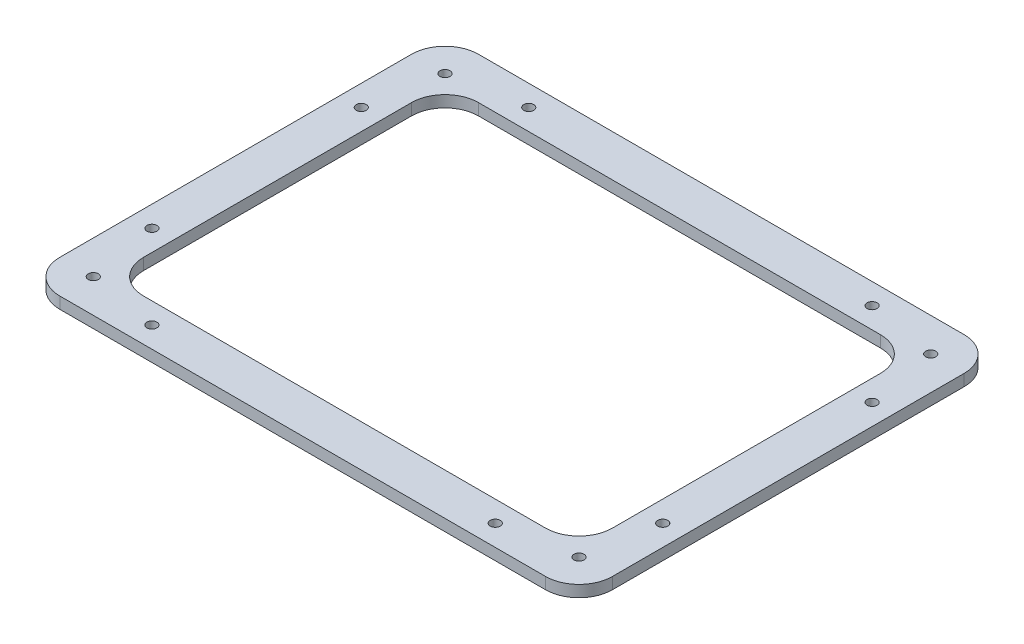
from build123d import *

# Parameters (mm, degrees)
SKETCH1_W           = 330
SKETCH1_H           = 250
BOSS_EXTRUDE1_DEPTH = 6.9
SKETCH2_R           = 3
CUT_EXTRUDE1_DEPTH  = 7.9
SKETCH3_W           = 280
SKETCH3_H           = 200
CUT_EXTRUDE2_DEPTH  = 7.9
FILLET1_R           = 20
FILLET2_R           = 20
SKETCH4_R           = 3
CUT_EXTRUDE3_DEPTH  = 7.9


with BuildPart() as part:
    # Sketch1 → Boss-Extrude1 (new body)
    with BuildSketch(Plane(origin=(0, 0, 0), x_dir=(1, 0, 0), z_dir=(0, 1, 0))):
        Rectangle(SKETCH1_W, SKETCH1_H)
    extrude(amount=BOSS_EXTRUDE1_DEPTH)

    # Sketch2 → Cut-Extrude1 (cut, through all)
    with BuildSketch(Plane(origin=(0, 6.9, 0), x_dir=(1, 0, 0), z_dir=(0, 1, 0))):
        with Locations((-145, 105)):
            Circle(SKETCH2_R)
        with Locations((145, 105)):
            Circle(SKETCH2_R)
        with Locations((145, -105)):
            Circle(SKETCH2_R)
        with Locations((-145, -105)):
            Circle(SKETCH2_R)
    extrude(amount=-CUT_EXTRUDE1_DEPTH, mode=Mode.SUBTRACT)

    # Sketch3 → Cut-Extrude2 (cut, through all)
    with BuildSketch(Plane(origin=(0, 6.9, 0), x_dir=(1, 0, 0), z_dir=(0, 1, 0))):
        Rectangle(SKETCH3_W, SKETCH3_H)
    extrude(amount=-CUT_EXTRUDE2_DEPTH, mode=Mode.SUBTRACT)

    # Fillet1
    fillet1_edges = [part.edges().sort_by_distance(p)[0] for p in [
        (-165, 3.45, -125),
        (165, 3.45, -125),
        (165, 3.45, 125),
        (-165, 3.45, 125),
    ]]
    fillet(fillet1_edges, radius=FILLET1_R)

    # Fillet2
    fillet2_edges = [part.edges().sort_by_distance(p)[0] for p in [
        (-140, 3.45, 100),
        (-140, 3.45, -100),
        (140, 3.45, -100),
        (140, 3.45, 100),
    ]]
    fillet(fillet2_edges, radius=FILLET2_R)

    # Sketch4 → Cut-Extrude3 (cut, through all)
    with BuildSketch(Plane(origin=(0, 6.9, 0), x_dir=(1, 0, 0), z_dir=(0, 1, 0))):
        with Locations((-152.5, -62.5)):
            Circle(SKETCH4_R)
        with Locations((-102.5, -112.5)):
            Circle(SKETCH4_R)
        with Locations((102.5, -112.5)):
            Circle(SKETCH4_R)
        with Locations((152.5, -62.5)):
            Circle(SKETCH4_R)
        with Locations((152.5, 62.5)):
            Circle(SKETCH4_R)
        with Locations((102.5, 112.5)):
            Circle(SKETCH4_R)
        with Locations((-102.5, 112.5)):
            Circle(SKETCH4_R)
        with Locations((-152.5, 62.5)):
            Circle(SKETCH4_R)
    extrude(amount=-CUT_EXTRUDE3_DEPTH, mode=Mode.SUBTRACT)


solid = part.part
